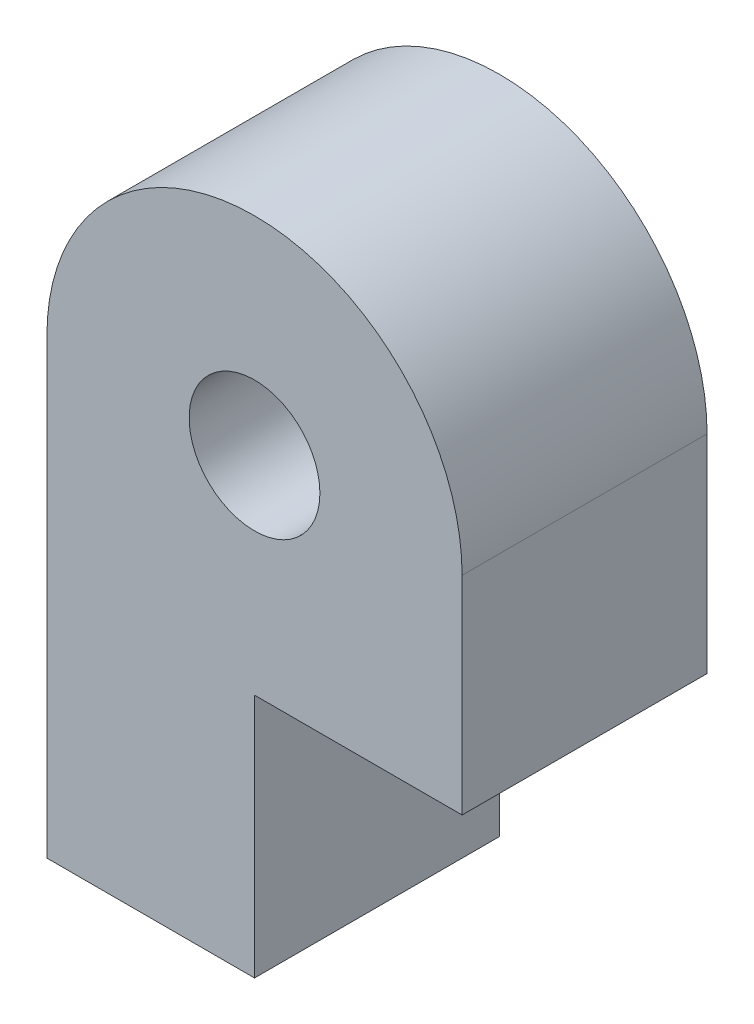
from build123d import *

# Parameters (mm, degrees)
SKETCH1_R           = 1.6
BOSS_EXTRUDE1_DEPTH = 5.9944


with BuildPart() as part:
    # Sketch1 → Boss-Extrude1 (new body)
    with BuildSketch(Plane.XY):
        with BuildLine():
            Line((-5.08, 0), (-5.08, -5.08))
            Line((-5.08, -5.08), (-5.08, -11.0744))
            Line((-5.08, -11.0744), (0, -11.0744))
            Line((0, -11.0744), (0, -5.08))
            Line((0, -5.08), (5.08, -5.08))
            Line((5.08, -5.08), (5.08, 0))
            ThreePointArc((5.08, 0), (0, 5.08), (-5.08, 0))
        make_face()
        Circle(SKETCH1_R, mode=Mode.SUBTRACT)
    extrude(amount=BOSS_EXTRUDE1_DEPTH)


solid = part.part
